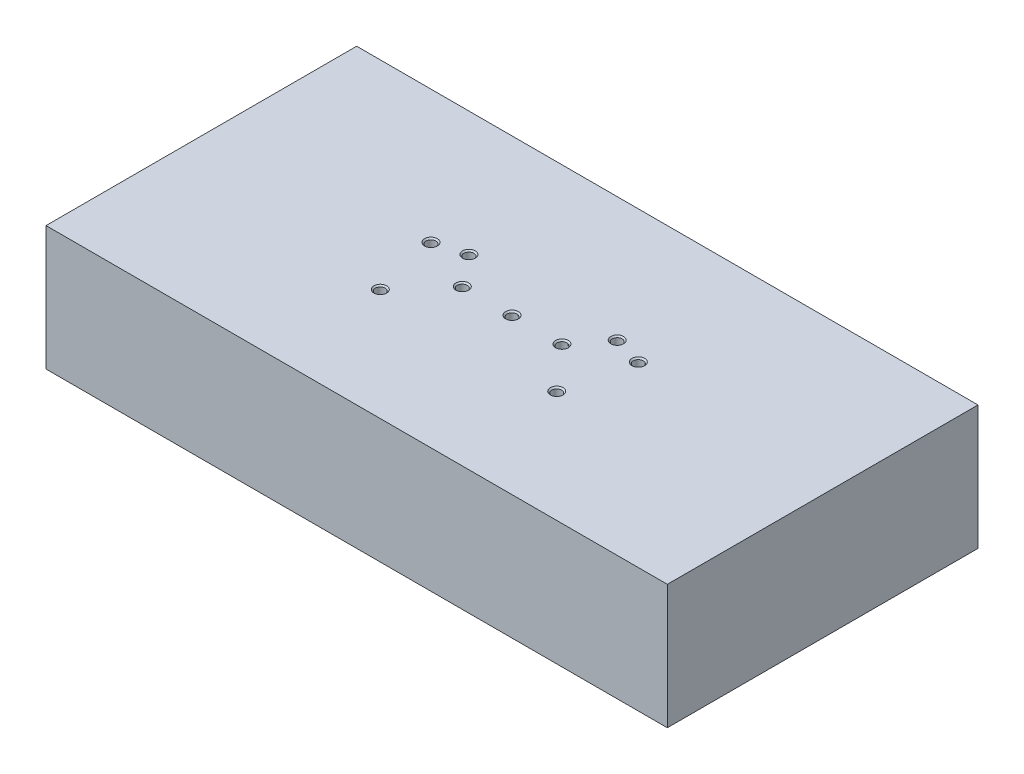
from build123d import *

# Parameters (mm, degrees)
SKETCH1_W                   = 100
SKETCH1_H                   = 50
SKETCH1_R                   = 0.5
BOSS_EXTRUDE6_DEPTH         = 10
SKETCH3_W                   = 100
SKETCH3_H                   = 50
BOSS_EXTRUDE7_DEPTH         = 10
M2_TAPPED_HOLE1_D           = 1.6
M2_TAPPED_HOLE1_DEPTH       = 20
M2_TAPPED_HOLE1_CSINK_D     = 2.05
M2_TAPPED_HOLE1_CSINK_ANGLE = 90
M2_TAPPED_HOLE1_TIP         = 0.480688495


with BuildPart() as part:
    # Sketch1 → Boss-Extrude6 (new body)
    with BuildSketch(Plane(origin=(0, 0, 0), x_dir=(1, 0, 0), z_dir=(0, 1, 0))):
        Rectangle(SKETCH1_W, SKETCH1_H)
        with Locations((-14.2, -7)):
            Circle(SKETCH1_R, mode=Mode.SUBTRACT)
        with Locations((14.2, -7)):
            Circle(SKETCH1_R, mode=Mode.SUBTRACT)
        with Locations((-16.685084167, 3.643524774)):
            Circle(SKETCH1_R, mode=Mode.SUBTRACT)
        with Locations((16.685084167, 3.643524774)):
            Circle(SKETCH1_R, mode=Mode.SUBTRACT)
        with Locations((-11.935084167, 5)):
            Circle(SKETCH1_R, mode=Mode.SUBTRACT)
        with Locations((11.935084167, 5)):
            Circle(SKETCH1_R, mode=Mode.SUBTRACT)
        Polygon((-11.7, 3), (-0.25, 3), (-0.25, 7), (0.25, 7), (0.25, 3), (11.7, 3), (11.7, -3), (-11.7, -3), align=None, mode=Mode.SUBTRACT)
    extrude(amount=BOSS_EXTRUDE6_DEPTH)

    # Sketch3 → Boss-Extrude7 (add)
    with BuildSketch(Plane(origin=(0, 10, 0), x_dir=(1, 0, 0), z_dir=(0, 1, 0))):
        Rectangle(SKETCH3_W, SKETCH3_H)
    extrude(amount=BOSS_EXTRUDE7_DEPTH)

    # M2 Tapped Hole1
    with Locations(Plane(origin=(0, 20, 0), x_dir=(1, 0, 0), z_dir=(0, 1, 0))):
        with Locations((-16.685084167, 3.643524774), (-11.935084167, 5), (11.935084167, 5), (16.685084167, 3.643524774), (14.2, -7), (-14.2, -7), (-8, 0), (8.042631754, 0), (0, 0)):
            CounterSinkHole(M2_TAPPED_HOLE1_D / 2, M2_TAPPED_HOLE1_CSINK_D / 2, depth=M2_TAPPED_HOLE1_DEPTH, counter_sink_angle=M2_TAPPED_HOLE1_CSINK_ANGLE)
            with Locations((0, 0, -(M2_TAPPED_HOLE1_DEPTH + M2_TAPPED_HOLE1_TIP / 2))):  # 118° drill point
                Cone(0, M2_TAPPED_HOLE1_D / 2, M2_TAPPED_HOLE1_TIP, mode=Mode.SUBTRACT)


solid = part.part
